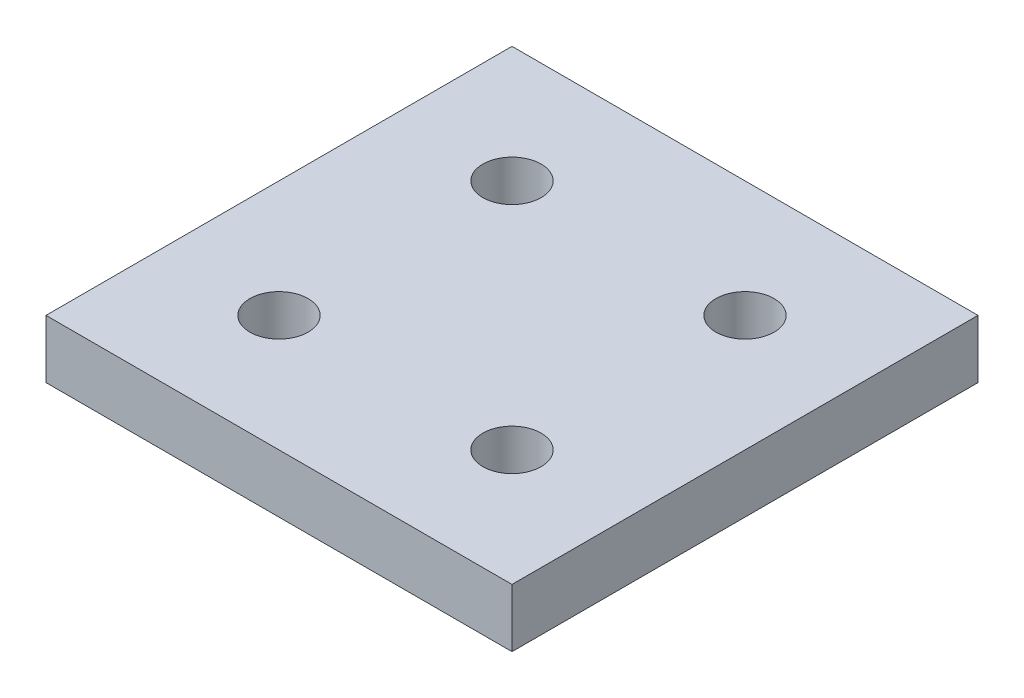
from build123d import *

# Parameters (mm, degrees)
SKETCH1_W           = 40
SKETCH1_H           = 40
SKETCH1_R           = 2.5
BOSS_EXTRUDE1_DEPTH = 5


with BuildPart() as part:
    # Sketch1 → Boss-Extrude1 (new body)
    with BuildSketch(Plane(origin=(0, 0, 0), x_dir=(1, 0, 0), z_dir=(0, 1, 0))):
        with Locations((20, -20)):
            Rectangle(SKETCH1_W, SKETCH1_H)
        with Locations((10, -10)):
            Circle(SKETCH1_R, mode=Mode.SUBTRACT)
        with Locations((30, -30)):
            Circle(SKETCH1_R, mode=Mode.SUBTRACT)
        with Locations((10, -30)):
            Circle(SKETCH1_R, mode=Mode.SUBTRACT)
        with Locations((30, -10)):
            Circle(SKETCH1_R, mode=Mode.SUBTRACT)
    extrude(amount=BOSS_EXTRUDE1_DEPTH)


solid = part.part
